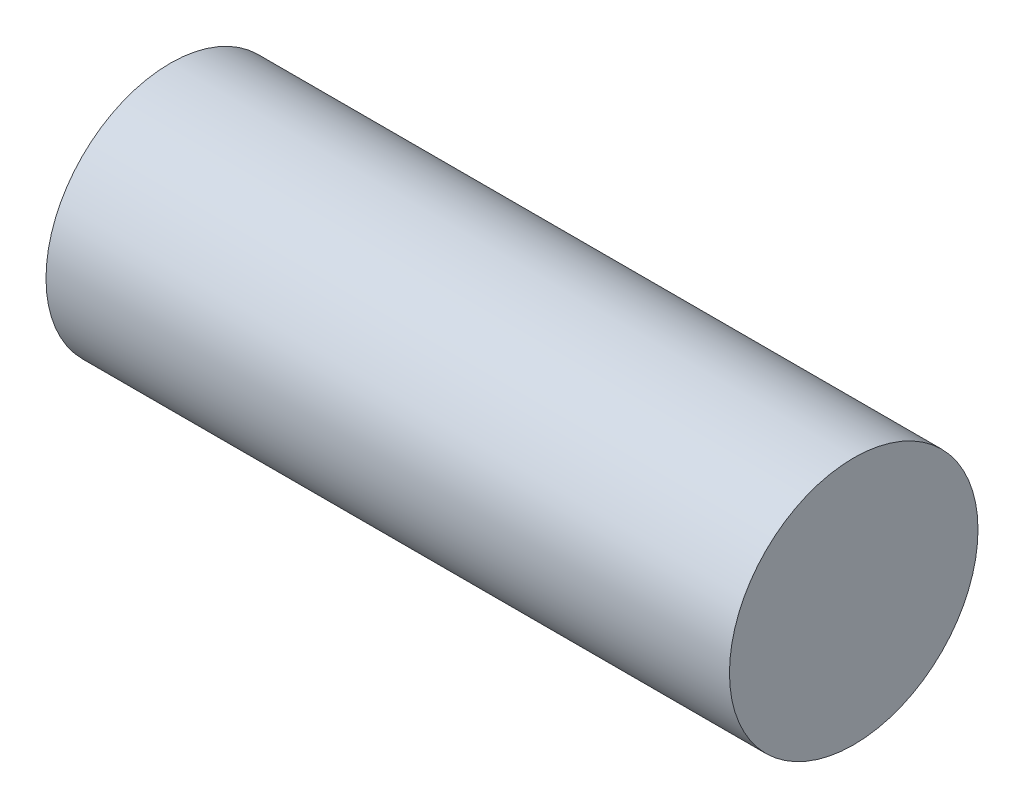
from build123d import *

# Parameters (mm, degrees)
SKETCH_1_R      = 4
EXTRUDE_1_DEPTH = 22


with BuildPart() as part:
    # 草图1 → 凸台-拉伸1 (new body)
    with BuildSketch(Plane(origin=(0, 0, 0), x_dir=(0, 0, -1), z_dir=(1, 0, 0))):
        Circle(SKETCH_1_R)
    extrude(amount=EXTRUDE_1_DEPTH)


solid = part.part
